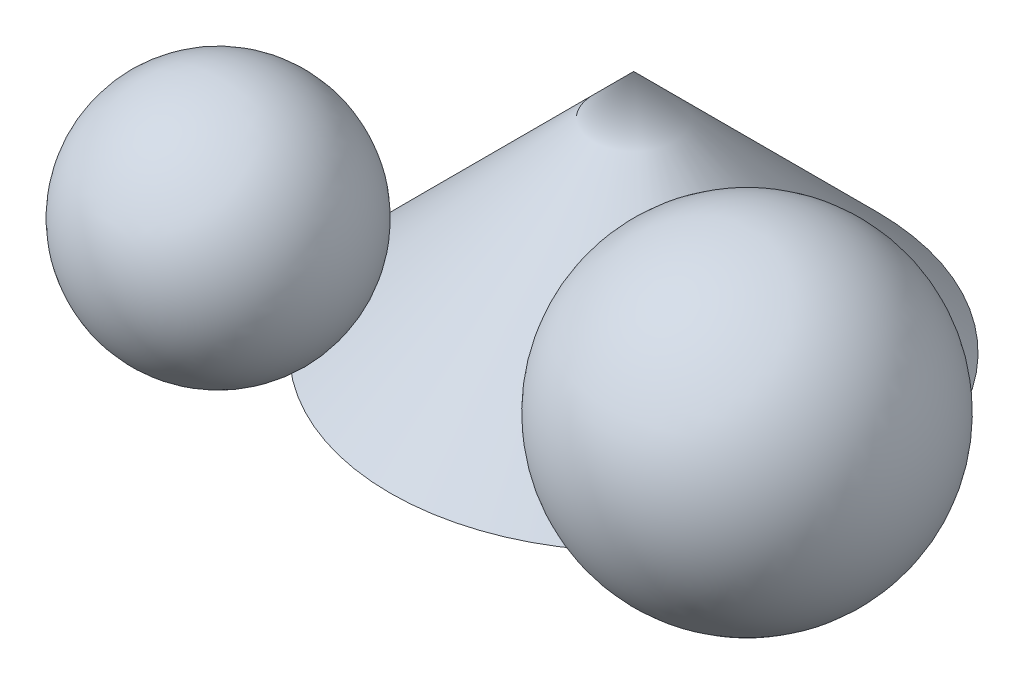
from build123d import *

# Parameters (mm, degrees)
SKETCH1_R = 40


with BuildPart() as part:
    # Sketch1 → Loft1 section 0
    with BuildSketch(Plane(origin=(0, 0, 0), x_dir=(1, 0, 0), z_dir=(0, 1, 0)), mode=Mode.PRIVATE) as loft1_s0:
        Circle(SKETCH1_R)
    loft([Vertex(0, 40, 0), loft1_s0.sketch])


with BuildPart() as body_2:
    # Sketch5 → Revolve1 (revolve)
    with BuildSketch(Plane(origin=(0, 20, 0), x_dir=(-1, 0, 0), z_dir=(0, 1, 0))):
        with BuildLine():
            Line((33.262153416, 55), (33.262153416, 15))
            ThreePointArc((33.262153416, 15), (53.262153416, 35), (33.262153416, 55))
        make_face()
    revolve(axis=Axis((-33.262153416, 20, 55), (0, 0, -1)))


with BuildPart() as body_3:
    # Sketch8 → Revolve2 (revolve)
    with BuildSketch(Plane(origin=(0, 0, 0), x_dir=(0.866025404, 0, 0.5), z_dir=(-0.5, 0, 0.866025404))):
        with BuildLine():
            Line((50.844733963, 52.363007627), (50.844733963, 0))
            ThreePointArc((50.844733963, 0), (24.663230149, 26.181503814), (50.844733963, 52.363007627))
        make_face()
    revolve(axis=Axis((44.032831261, 52.363007627, 25.422366981), (0, -1, 0)))


solid = Compound([part.part, body_2.part, body_3.part])
